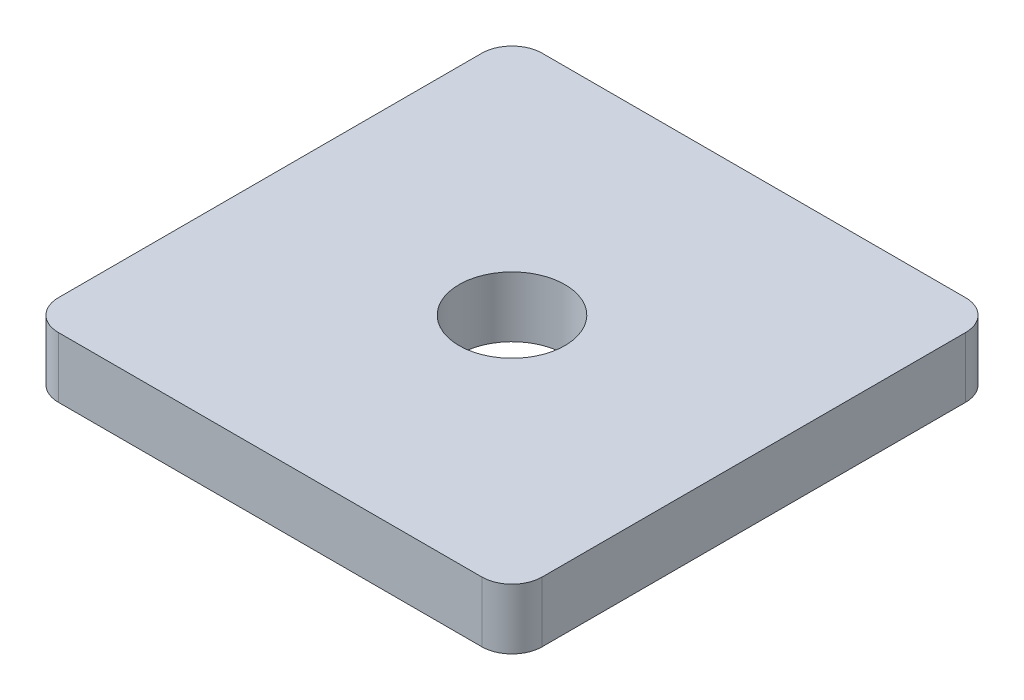
from build123d import *

# Parameters (mm, degrees)
SKETCH1_W           = 16
SKETCH1_H           = 16
BOSS_EXTRUDE1_DEPTH = 2
FILLET1_R           = 1
SKETCH2_R           = 1.75
CUT_EXTRUDE1_DEPTH  = 12.489125293


with BuildPart() as part:
    # Sketch1 → Boss-Extrude1 (new body)
    with BuildSketch(Plane(origin=(0, 0, 0), x_dir=(1, 0, 0), z_dir=(0, 1, 0))):
        Rectangle(SKETCH1_W, SKETCH1_H)
    extrude(amount=BOSS_EXTRUDE1_DEPTH)

    # Fillet1
    fillet1_edges = [part.edges().sort_by_distance(p)[0] for p in [
        (-8, 1, -8),
        (-8, 1, 8),
        (8, 1, -8),
        (8, 1, 8),
    ]]
    fillet(fillet1_edges, radius=FILLET1_R)

    # Sketch2 → Cut-Extrude1 (cut, through all)
    with BuildSketch(Plane(origin=(0, 2, 0), x_dir=(1, 0, 0), z_dir=(0, 1, 0))):
        Circle(SKETCH2_R)
    extrude(amount=-CUT_EXTRUDE1_DEPTH, mode=Mode.SUBTRACT)


solid = part.part
